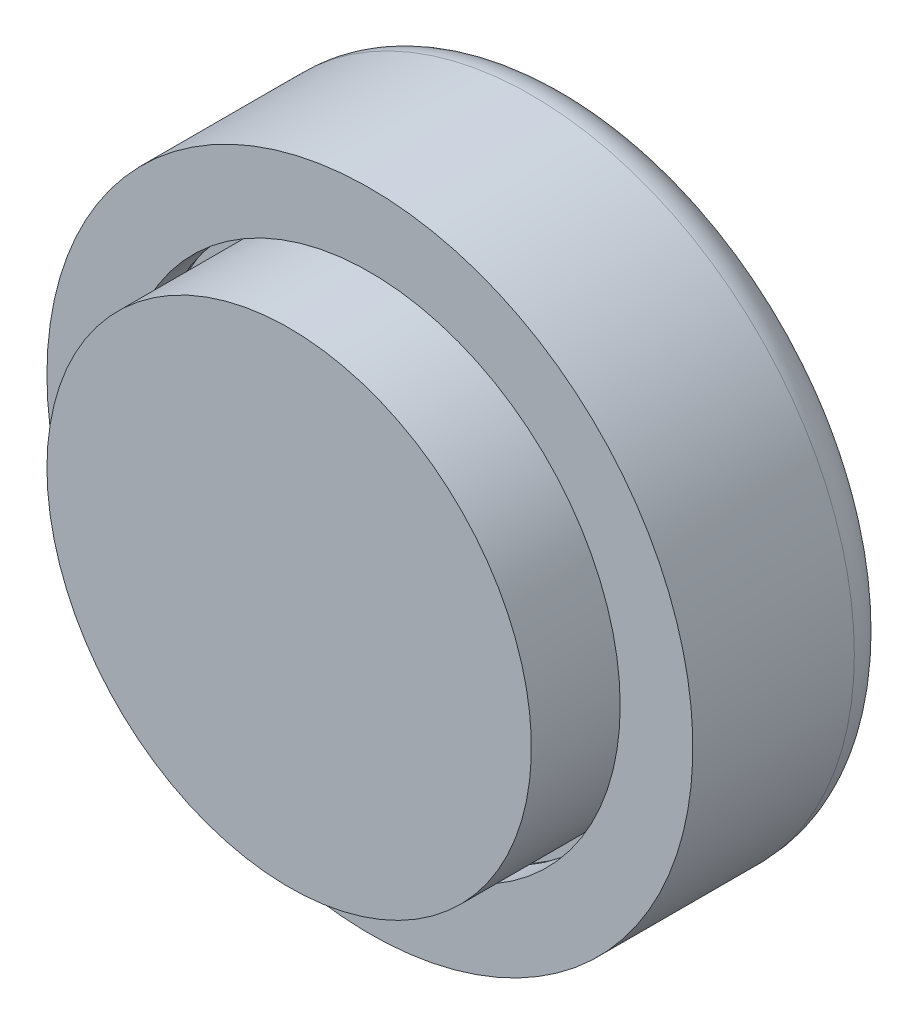
from build123d import *

# Parameters (mm, degrees)
CUT_EXTRUDE2_DEPTH  = 0.4
FILLET1_R           = 1
SKETCH5_W           = 2
SKETCH5_H           = 1.5
BOSS_EXTRUDE1_DEPTH = 3
SKETCH6_W           = 2.4
SKETCH6_H           = 1.9
CUT_EXTRUDE3_DEPTH  = 3


with BuildPart() as part:
    # Sketch3 → Revolve3 (revolve)
    with BuildSketch(Plane(origin=(0, 0, 0), x_dir=(1, 0, 0), z_dir=(0, 1, 0))):
        Polygon((4, 1), (0, 1), (0, 0), (6, 0), (6, 3), (6.25, 3), (6.25, 4), (4, 4), align=None)
    revolve(axis=Axis((0, 0, 0), (0, 0, 1)))

    # Sketch6 → Cut-Extrude3 (cut)
    with BuildSketch(Plane(origin=(0, 0, -4), x_dir=(-1, 0, 0), z_dir=(0, 0, -1))):
        with Locations((0, 3.75)):
            Rectangle(SKETCH6_W, SKETCH6_H)
    extrude(amount=-CUT_EXTRUDE3_DEPTH, mode=Mode.SUBTRACT)


with BuildPart() as body_2:
    # Sketch3_3 → Revolve4 (revolve)
    with BuildSketch(Plane(origin=(0, 0, 0), x_dir=(1, 0, 0), z_dir=(0, 1, 0))):
        Polygon((3.5, 6), (6.45, 6), (6.45, 2.8), (6.2, 2.8), (6.2, 2), (8, 2), (8, 7), (0, 7), (0, 4), (3.5, 4), align=None)
    revolve(axis=Axis((0, 0, 0), (0, 0, 1)))

    # Sketch4 → Cut-Extrude2 (cut)
    with BuildSketch(Plane(origin=(0, 0, -7), x_dir=(-1, 0, 0), z_dir=(0, 0, -1))):
        with BuildLine():
            Line((-5.935897436, 2), (-4.783653846, 2))
            add(Edge.make_bspline(
                [(-4.783653846, 2), (-4.693631454, 1.999507936), (-4.519664687, 1.998557032), (-4.267690515, 1.987819727), (-4.033840509, 1.971383049), (-3.81777643, 1.94858298), (-3.619548124, 1.918531451), (-3.438995265, 1.881016231), (-3.276093905, 1.837526623), (-3.129144069, 1.786690398), (-2.995052528, 1.726648147), (-2.867941675, 1.660570752), (-2.747585912, 1.584615444), (-2.632460833, 1.50118384), (-2.523299478, 1.408939465), (-2.420701205, 1.307721024), (-2.324427664, 1.198191953), (-2.233893756, 1.081662851), (-2.151624726, 0.958277115), (-2.079737005, 0.828697775), (-2.019994263, 0.693566906), (-1.969370774, 0.553832901), (-1.932723299, 0.408102895), (-1.903849666, 0.258166783), (-1.888019043, 0.102637917), (-1.885761562, -0.002638417), (-1.884615385, -0.056089744)],
                knots=[0, 0, 0, 0, 0.000270051, 0.000521869, 0.000756448, 0.000973242, 0.001173487, 0.001357667, 0.001526191, 0.001679001, 0.001823574, 0.001966582, 0.002108425, 0.002250107, 0.002392819, 0.002536737, 0.002682068, 0.002830002, 0.002979122, 0.003126527, 0.003273948, 0.003421958, 0.003571799, 0.003724241, 0.003879717, 0.004040071, 0.004040071, 0.004040071, 0.004040071], degree=3))
            add(Edge.make_bspline(
                [(-1.884615385, -0.056089744), (-1.885283849, -0.094300139), (-1.886603857, -0.16975366), (-1.895538904, -0.281872312), (-1.910684918, -0.391583215), (-1.932271527, -0.499187768), (-1.96057477, -0.60420786), (-1.994184113, -0.707333631), (-2.034217148, -0.807878586), (-2.079855351, -0.905869464), (-2.131423308, -1.00030819), (-2.186996237, -1.091658042), (-2.248413056, -1.178128576), (-2.313243915, -1.261364616), (-2.383711742, -1.339489517), (-2.458877758, -1.413563944), (-2.537803379, -1.484286887), (-2.649870088, -1.571027074), (-2.796084049, -1.668884018), (-2.980212016, -1.768169884), (-3.171927733, -1.847163023), (-3.340048293, -1.896647023), (-3.486242512, -1.92790345), (-3.614851042, -1.946030624), (-3.761490919, -1.963113974), (-3.926702141, -1.97599835), (-4.110446993, -1.98773951), (-4.312736239, -1.993997191), (-4.533359002, -1.999278717), (-4.686427544, -1.99975324), (-4.766025641, -2)],
                knots=[0, 0, 0, 0, 0.000114628, 0.000226355, 0.000337181, 0.000446711, 0.00055536, 0.000663305, 0.000771925, 0.000879825, 0.000987388, 0.00109458, 0.001200398, 0.001305393, 0.001410932, 0.001515753, 0.001621888, 0.00172864, 0.001940652, 0.00214894, 0.002355179, 0.002561559, 0.002673767, 0.002803406, 0.002951003, 0.003116628, 0.003300464, 0.003503317, 0.003723722, 0.003962509, 0.003962509, 0.003962509, 0.003962509], degree=3))
            Line((-4.766025641, -2), (-5.935897436, -2))
            Line((-5.935897436, -2), (-5.935897436, 2))
        make_face()
        with BuildLine():
            Line((-5.012820513, 1.282051282), (-5.012820513, -1.282051282))
            Line((-5.012820513, -1.282051282), (-4.539262821, -1.282051282))
            add(Edge.make_bspline(
                [(-4.539262821, -1.282051282), (-4.482894633, -1.281963279), (-4.374124231, -1.281793465), (-4.217096289, -1.274344213), (-4.071854555, -1.266823298), (-3.938879485, -1.252488816), (-3.81773814, -1.236922739), (-3.709246063, -1.214283664), (-3.611795971, -1.191614624), (-3.52555326, -1.161918542), (-3.446786811, -1.128494345), (-3.373224139, -1.089982059), (-3.302939808, -1.046494332), (-3.236539695, -0.997663637), (-3.173883082, -0.943537502), (-3.114171666, -0.885133922), (-3.058839356, -0.820490379), (-3.00719198, -0.751172232), (-2.959149187, -0.677770516), (-2.919777666, -0.598753399), (-2.884834505, -0.516467099), (-2.855831966, -0.430076229), (-2.834395912, -0.339084795), (-2.819451311, -0.243974654), (-2.809429806, -0.144977618), (-2.808276773, -0.077482215), (-2.807692308, -0.043269231)],
                knots=[0, 0, 0, 0, 0.000169078, 0.00032626, 0.00047156, 0.000605268, 0.000727426, 0.000837742, 0.000937632, 0.001027333, 0.001110978, 0.001194126, 0.001276174, 0.00135871, 0.001441102, 0.001524393, 0.001609045, 0.001696064, 0.001783639, 0.001871795, 0.001960491, 0.002051711, 0.002144804, 0.002240574, 0.002340397, 0.002443011, 0.002443011, 0.002443011, 0.002443011], degree=3))
            add(Edge.make_bspline(
                [(-2.807692308, -0.043269231), (-2.808950526, 0.009163549), (-2.811408609, 0.111597399), (-2.83430769, 0.26080987), (-2.872044307, 0.401061358), (-2.923978678, 0.532710638), (-2.991869881, 0.654581023), (-3.0748585, 0.766963046), (-3.17170325, 0.871550611), (-3.247015121, 0.93123326), (-3.28525641, 0.961538462)],
                knots=[0, 0, 0, 0, 0.000157217, 0.000307142, 0.000451562, 0.000592173, 0.000730628, 0.000868776, 0.001010497, 0.001156693, 0.001156693, 0.001156693, 0.001156693], degree=3))
            add(Edge.make_bspline(
                [(-3.28525641, 0.961538462), (-3.323102566, 0.987681494), (-3.401401635, 1.041768233), (-3.535442758, 1.105182279), (-3.68409476, 1.160807611), (-3.849527774, 1.204994446), (-4.03076493, 1.240156147), (-4.228381198, 1.264130146), (-4.442053103, 1.279812808), (-4.589980251, 1.281287034), (-4.666666667, 1.282051282)],
                knots=[0, 0, 0, 0, 0.000137793, 0.000285076, 0.000443288, 0.000613569, 0.000798059, 0.000996734, 0.001210418, 0.001440436, 0.001440436, 0.001440436, 0.001440436], degree=3))
            Line((-4.666666667, 1.282051282), (-5.012820513, 1.282051282))
        make_face(mode=Mode.SUBTRACT)
        with BuildLine():
            Line((-1.025641026, 2), (0.037660256, 2))
            add(Edge.make_bspline(
                [(0.037660256, 2), (0.107910945, 1.999800927), (0.243095112, 1.999417847), (0.437836713, 1.993500705), (0.6168733, 1.985137558), (0.780179211, 1.972597622), (0.927953358, 1.955788126), (1.060037686, 1.936030702), (1.176632274, 1.913529048), (1.279026246, 1.885654227), (1.371289838, 1.853844733), (1.457283078, 1.817834012), (1.538581975, 1.776694971), (1.615588938, 1.731176421), (1.687961309, 1.680597428), (1.755503857, 1.624897088), (1.818968631, 1.564903671), (1.877349485, 1.500041033), (1.930065389, 1.431590465), (1.97632795, 1.359548573), (2.015354885, 1.284417549), (2.048018294, 1.206352811), (2.071722152, 1.124750481), (2.089156628, 1.040625573), (2.101272412, 0.953339665), (2.102128184, 0.894005882), (2.102564103, 0.863782051)],
                knots=[0, 0, 0, 0, 0.000210743, 0.000405536, 0.000584439, 0.000748402, 0.000896795, 0.001030516, 0.001149003, 0.001252802, 0.001348588, 0.001441599, 0.00153226, 0.001621721, 0.001709749, 0.001796853, 0.001884138, 0.001971511, 0.002058375, 0.002143061, 0.002228001, 0.002312074, 0.002396498, 0.00248246, 0.002569722, 0.002660324, 0.002660324, 0.002660324, 0.002660324], degree=3))
            add(Edge.make_bspline(
                [(2.102564103, 0.863782051), (2.10176613, 0.832230566), (2.100198844, 0.770260811), (2.088704096, 0.679379764), (2.070378059, 0.592481906), (2.044665179, 0.509202563), (2.011135357, 0.42997409), (1.969561451, 0.354891916), (1.92189253, 0.283111103), (1.864770116, 0.216622621), (1.801829414, 0.153013915), (1.730257997, 0.094382116), (1.652065449, 0.039011626), (1.565365823, -0.011375959), (1.471784859, -0.058635178), (1.370532422, -0.10170916), (1.262017294, -0.141339968), (1.186306169, -0.163369482), (1.147435897, -0.174679487)],
                knots=[0, 0, 0, 0, 9.4636e-05, 0.000185873, 0.000274352, 0.000360776, 0.000446946, 0.000531935, 0.000617941, 0.000704942, 0.000794464, 0.00088608, 0.000982117, 0.001081612, 0.001186607, 0.00129645, 0.001411528, 0.001532946, 0.001532946, 0.001532946, 0.001532946], degree=3))
            Line((1.147435897, -0.174679487), (2.333333333, -2))
            Line((2.333333333, -2), (1.297275641, -2))
            Line((1.297275641, -2), (0.165064103, -0.256410256))
            Line((0.165064103, -0.256410256), (-0.102564103, -0.256410256))
            Line((-0.102564103, -0.256410256), (-0.102564103, -2))
            Line((-0.102564103, -2), (-1.025641026, -2))
            Line((-1.025641026, -2), (-1.025641026, 2))
        make_face()
        with BuildLine():
            Line((-0.102564103, 0.461538462), (0.246794872, 0.461538462))
            add(Edge.make_bspline(
                [(0.246794872, 0.461538462), (0.289530785, 0.461923253), (0.371283033, 0.462659345), (0.488909576, 0.466078679), (0.596037973, 0.474368418), (0.692783254, 0.484617701), (0.77939372, 0.496765087), (0.855247718, 0.513836961), (0.921488082, 0.532364706), (0.977786473, 0.555182583), (1.026025431, 0.580712881), (1.06680243, 0.610986414), (1.101591424, 0.644921388), (1.130968899, 0.682544876), (1.152797091, 0.725061804), (1.167663911, 0.771131837), (1.177936041, 0.820867628), (1.178957102, 0.855446187), (1.179487179, 0.873397436)],
                knots=[0, 0, 0, 0, 0.000128215, 0.000245271, 0.000352941, 0.000450454, 0.000537145, 0.000615104, 0.000683566, 0.000743233, 0.000797015, 0.000846855, 0.000895019, 0.000942457, 0.000989406, 0.00103755, 0.001087365, 0.001141146, 0.001141146, 0.001141146, 0.001141146], degree=3))
            add(Edge.make_bspline(
                [(1.179487179, 0.873397436), (1.17822072, 0.894627121), (1.1757183, 0.936575267), (1.156679038, 0.997211614), (1.124303299, 1.052651324), (1.080620333, 1.103148696), (1.026487476, 1.147873609), (0.963626658, 1.18639626), (0.89218373, 1.217732543), (0.826037668, 1.237620242), (0.76544837, 1.250150046), (0.710653215, 1.25885643), (0.646973324, 1.265685788), (0.574875914, 1.272296209), (0.49416665, 1.276853468), (0.404672054, 1.28008029), (0.306627521, 1.281399162), (0.238247923, 1.281828328), (0.202724359, 1.282051282)],
                knots=[0, 0, 0, 0, 6.3625e-05, 0.000125718, 0.00018853, 0.000255018, 0.000324987, 0.000398373, 0.0004755, 0.000558389, 0.000605063, 0.00066105, 0.000724761, 0.000797161, 0.000878233, 0.000967233, 0.001065803, 0.001172377, 0.001172377, 0.001172377, 0.001172377], degree=3))
            Line((0.202724359, 1.282051282), (-0.102564103, 1.282051282))
            Line((-0.102564103, 1.282051282), (-0.102564103, 0.461538462))
        make_face(mode=Mode.SUBTRACT)
        with BuildLine():
            Line((5.679487179, 1.465544872), (4.970352564, 0.974358974))
            add(Edge.make_bspline(
                [(4.970352564, 0.974358974), (4.939566807, 1.006876869), (4.880026335, 1.06976734), (4.785871635, 1.153604302), (4.691265124, 1.224441584), (4.596280613, 1.282919267), (4.500413406, 1.328370057), (4.403844523, 1.360520311), (4.306937806, 1.380846591), (4.242081865, 1.383366424), (4.209935897, 1.384615385)],
                knots=[0, 0, 0, 0, 0.000134293, 0.000259726, 0.000377675, 0.000488438, 0.000593821, 0.000695176, 0.000793234, 0.000889602, 0.000889602, 0.000889602, 0.000889602], degree=3))
            add(Edge.make_bspline(
                [(4.209935897, 1.384615385), (4.179954286, 1.383824749), (4.12223809, 1.382302735), (4.039815516, 1.367041396), (3.965987617, 1.341403311), (3.902080983, 1.306593216), (3.850544881, 1.265331118), (3.810618804, 1.221743906), (3.786377296, 1.173147874), (3.783465409, 1.139120967), (3.782051282, 1.122596154)],
                knots=[0, 0, 0, 0, 8.9872e-05, 0.000173009, 0.000250303, 0.000323461, 0.00039016, 0.000447523, 0.000499853, 0.00054926, 0.00054926, 0.00054926, 0.00054926], degree=3))
            add(Edge.make_bspline(
                [(3.782051282, 1.122596154), (3.783220794, 1.105914702), (3.785593579, 1.072070259), (3.802539706, 1.022329828), (3.830318396, 0.974368035), (3.85549086, 0.945902321), (3.868589744, 0.931089744)],
                knots=[0, 0, 0, 0, 4.9995e-05, 0.000101433, 0.000155997, 0.000215194, 0.000215194, 0.000215194, 0.000215194], degree=3))
            add(Edge.make_bspline(
                [(3.868589744, 0.931089744), (3.880729494, 0.919438533), (3.908889521, 0.892411751), (3.961283832, 0.850627481), (4.026540424, 0.797800484), (4.108668119, 0.738982226), (4.203757743, 0.669232166), (4.314988778, 0.593066418), (4.439476245, 0.505930055), (4.528460586, 0.446408612), (4.575320513, 0.415064103)],
                knots=[0, 0, 0, 0, 5.0455e-05, 0.000117039, 0.000200883, 0.00030233, 0.000419977, 0.000554678, 0.00070671, 0.000875834, 0.000875834, 0.000875834, 0.000875834], degree=3))
            add(Edge.make_bspline(
                [(4.575320513, 0.415064103), (4.619152474, 0.385993758), (4.702124681, 0.330964721), (4.819603775, 0.252105301), (4.923395662, 0.181701271), (5.014266996, 0.120206276), (5.090932215, 0.066410439), (5.154563645, 0.021726734), (5.20420282, -0.014953692), (5.232409553, -0.037076975), (5.244391026, -0.046474359)],
                knots=[0, 0, 0, 0, 0.000157787, 0.000298686, 0.000424474, 0.000534042, 0.000627847, 0.000705439, 0.000767299, 0.000812979, 0.000812979, 0.000812979, 0.000812979], degree=3))
            add(Edge.make_bspline(
                [(5.244391026, -0.046474359), (5.290132406, -0.084524953), (5.377270156, -0.157011684), (5.492092379, -0.270822662), (5.586693136, -0.381705792), (5.660531312, -0.492118278), (5.715201435, -0.604161695), (5.754635326, -0.719469484), (5.777062239, -0.840208919), (5.780378462, -0.922454663), (5.782051282, -0.963942308)],
                knots=[0, 0, 0, 0, 0.000178429, 0.000339909, 0.000484362, 0.000615037, 0.000737237, 0.000857344, 0.000979612, 0.001104069, 0.001104069, 0.001104069, 0.001104069], degree=3))
            add(Edge.make_bspline(
                [(5.782051282, -0.963942308), (5.78102209, -1.004376227), (5.778996944, -1.083938254), (5.756887992, -1.200300924), (5.723611393, -1.311228444), (5.676647262, -1.417063795), (5.614790909, -1.516489363), (5.541116274, -1.611765073), (5.452357714, -1.700131764), (5.352092351, -1.78285368), (5.240768968, -1.858021901), (5.120354306, -1.923824188), (4.991757356, -1.979027761), (4.855006565, -2.024194801), (4.710201468, -2.058939419), (4.557374514, -2.084668173), (4.396421902, -2.100143924), (4.286359561, -2.10174419), (4.229967949, -2.102564103)],
                knots=[0, 0, 0, 0, 0.000121163, 0.000238414, 0.000353998, 0.000468062, 0.000584598, 0.000704491, 0.000828576, 0.000959487, 0.001093943, 0.001230922, 0.001370541, 0.001513198, 0.001662454, 0.001816842, 0.00197782, 0.002146959, 0.002146959, 0.002146959, 0.002146959], degree=3))
            add(Edge.make_bspline(
                [(4.229967949, -2.102564103), (4.185612313, -2.101972056), (4.098396625, -2.100807925), (3.969742509, -2.090917127), (3.845351463, -2.075018399), (3.725180146, -2.052729867), (3.609334572, -2.023759951), (3.497909791, -1.988693557), (3.390911593, -1.946757958), (3.287897294, -1.898741465), (3.189073648, -1.843283454), (3.094206665, -1.780356661), (3.002750179, -1.710694897), (2.914957388, -1.633278428), (2.831219689, -1.548399751), (2.75059065, -1.456447705), (2.673535968, -1.35732921), (2.626435375, -1.286631778), (2.602564103, -1.250801282)],
                knots=[0, 0, 0, 0, 0.000133051, 0.000261617, 0.000386845, 0.000509113, 0.000628049, 0.000744874, 0.000859301, 0.000972574, 0.00108558, 0.001198921, 0.001313829, 0.001430214, 0.001549766, 0.001671276, 0.001796931, 0.00192606, 0.00192606, 0.00192606, 0.00192606], degree=3))
            Line((2.602564103, -1.250801282), (3.419871795, -0.871794872))
            add(Edge.make_bspline(
                [(3.419871795, -0.871794872), (3.450342482, -0.912504136), (3.509369226, -0.991364691), (3.607803872, -1.095312437), (3.708176542, -1.185279162), (3.813518307, -1.257333612), (3.921868846, -1.314768139), (4.034109304, -1.354866012), (4.149788356, -1.380083026), (4.228238935, -1.383100394), (4.267628205, -1.384615385)],
                knots=[0, 0, 0, 0, 0.000152431, 0.000295284, 0.000428704, 0.000556058, 0.000677197, 0.000795562, 0.00091264, 0.0010307, 0.0010307, 0.0010307, 0.0010307], degree=3))
            add(Edge.make_bspline(
                [(4.267628205, -1.384615385), (4.307808053, -1.383358931), (4.385586613, -1.380926737), (4.496904545, -1.358612019), (4.598969402, -1.324040643), (4.687417075, -1.273375303), (4.762122218, -1.215637452), (4.817552659, -1.150944151), (4.853133027, -1.080189181), (4.85704139, -1.030288484), (4.858974359, -1.005608974)],
                knots=[0, 0, 0, 0, 0.000120408, 0.000233082, 0.000339266, 0.000442233, 0.000537465, 0.000621079, 0.000696352, 0.000770009, 0.000770009, 0.000770009, 0.000770009], degree=3))
            add(Edge.make_bspline(
                [(4.858974359, -1.005608974), (4.857379883, -0.982695677), (4.854106116, -0.935650259), (4.827789705, -0.866482758), (4.787828124, -0.797302179), (4.740852977, -0.741159753), (4.69256497, -0.694668208), (4.646614084, -0.65341731), (4.590584088, -0.608161035), (4.524582188, -0.558555408), (4.449270338, -0.504410174), (4.365141943, -0.444578456), (4.270346811, -0.381729873), (4.203822598, -0.338360948), (4.169070513, -0.315705128)],
                knots=[0, 0, 0, 0, 6.8579e-05, 0.000140805, 0.000219421, 0.000307653, 0.000359216, 0.000420502, 0.000492835, 0.000575208, 0.00066817, 0.0007711, 0.000884885, 0.001009342, 0.001009342, 0.001009342, 0.001009342], degree=3))
            add(Edge.make_bspline(
                [(4.169070513, -0.315705128), (4.102963585, -0.27264026), (3.976273833, -0.190109158), (3.796508944, -0.068381553), (3.63526212, 0.046032722), (3.492572137, 0.153187759), (3.368195671, 0.252750032), (3.260960531, 0.343213634), (3.173370081, 0.427674379), (3.101316476, 0.505110923), (3.043696415, 0.579818561), (2.99375668, 0.652075017), (2.953553892, 0.725401283), (2.918040021, 0.797566191), (2.891755192, 0.870452402), (2.873235787, 0.943196534), (2.861480993, 1.015645669), (2.859806998, 1.064059936), (2.858974359, 1.088141026)],
                knots=[0, 0, 0, 0, 0.000236688, 0.000453597, 0.000651256, 0.000829781, 0.000988833, 0.001129195, 0.001250467, 0.001353686, 0.001446171, 0.00153329, 0.001616877, 0.001696801, 0.001774364, 0.001848797, 0.00192178, 0.001994006, 0.001994006, 0.001994006, 0.001994006], degree=3))
            add(Edge.make_bspline(
                [(2.858974359, 1.088141026), (2.86021114, 1.122420693), (2.862654635, 1.190146671), (2.8820372, 1.289660252), (2.911955889, 1.386007321), (2.957134501, 1.477404103), (3.012790389, 1.565891361), (3.081493792, 1.649948518), (3.162202916, 1.730586136), (3.254702675, 1.805628969), (3.355817513, 1.875082365), (3.464083998, 1.936112836), (3.578511829, 1.987327478), (3.698166282, 2.03007987), (3.823660061, 2.062864813), (3.954949393, 2.086054428), (4.092124455, 2.099697086), (4.185599655, 2.101597104), (4.233173077, 2.102564103)],
                knots=[0, 0, 0, 0, 0.000102764, 0.00020303, 0.000303126, 0.000404548, 0.000507916, 0.000616164, 0.000729482, 0.000849624, 0.000972974, 0.001097111, 0.001221915, 0.001348635, 0.00147788, 0.00161054, 0.001748234, 0.001890944, 0.001890944, 0.001890944, 0.001890944], degree=3))
            add(Edge.make_bspline(
                [(4.233173077, 2.102564103), (4.294962753, 2.100849626), (4.417474008, 2.09745031), (4.598588076, 2.070859596), (4.77526748, 2.028519118), (4.918906598, 1.978023293), (5.033052644, 1.928160095), (5.120507951, 1.88309891), (5.2093101, 1.830397098), (5.30105241, 1.772564913), (5.392791496, 1.705066896), (5.487603965, 1.632485071), (5.583801307, 1.552244207), (5.647103955, 1.494886759), (5.679487179, 1.465544872)],
                knots=[0, 0, 0, 0, 0.000185306, 0.000367409, 0.000547955, 0.000729655, 0.000823299, 0.000921491, 0.001024561, 0.001133031, 0.001246672, 0.001366073, 0.001491238, 0.001622327, 0.001622327, 0.001622327, 0.001622327], degree=3))
        make_face()
    extrude(amount=-CUT_EXTRUDE2_DEPTH, mode=Mode.SUBTRACT)

    # Fillet1
    fillet1_edges = [body_2.edges().sort_by_distance(p)[0] for p in [
        (-8, 0, -7),
    ]]
    fillet(fillet1_edges, radius=FILLET1_R)

    # Sketch5 → Boss-Extrude1 (add)
    with BuildSketch(Plane.XY.offset(-6)):
        with Locations((0, 3.75)):
            Rectangle(SKETCH5_W, SKETCH5_H)
    extrude(amount=BOSS_EXTRUDE1_DEPTH)


solid = Compound([part.part, body_2.part])
